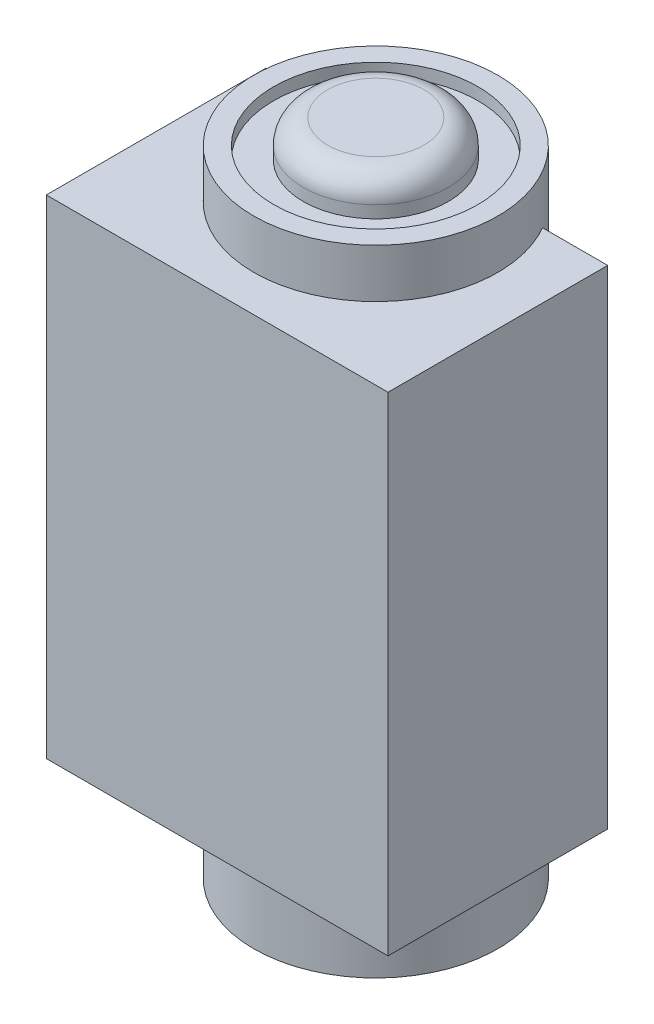
from build123d import *

# Parameters (mm, degrees)
BOSS_EXTRUDE1_DEPTH = 20
BOSS_EXTRUDE2_START = -4
SKETCH2_R           = 5
BOSS_EXTRUDE2_DEPTH = 26
SKETCH3_R           = 4.186334937
CUT_EXTRUDE1_DEPTH  = 0.5
SKETCH4_R           = 2.971370829
BOSS_EXTRUDE3_DEPTH = 1.5
FILLET1_R           = 1
SKETCH5_R           = 4.405236738
CUT_EXTRUDE2_DEPTH  = 0.25
SKETCH6_R           = 4.191211996
BOSS_EXTRUDE4_DEPTH = 0.25


with BuildPart() as part:
    # Sketch1 → Boss-Extrude1 (new body)
    with BuildSketch(Plane(origin=(0, 0, 0), x_dir=(1, 0, 0), z_dir=(0, 1, 0))):
        with BuildLine():
            Line((-4.330127019, 4.5), (-7, 4.5))
            Line((-7, 4.5), (-7, -4.5))
            Line((-7, -4.5), (7, -4.5))
            Line((7, -4.5), (7, 4.5))
            Line((7, 4.5), (4.330127019, 4.5))
            ThreePointArc((4.330127019, 4.5), (0, -3), (-4.330127019, 4.5))
        make_face()
    extrude(amount=BOSS_EXTRUDE1_DEPTH)


with BuildPart() as body_2:
    # Sketch2 → Boss-Extrude2 (new body)
    with BuildSketch(Plane(origin=(0, 0, 0), x_dir=(1, 0, 0), z_dir=(0, 1, 0)).offset(BOSS_EXTRUDE2_START)):
        with Locations((0, 2)):
            Circle(SKETCH2_R)
    extrude(amount=BOSS_EXTRUDE2_DEPTH)

    # Sketch3 → Cut-Extrude1 (cut)
    with BuildSketch(Plane(origin=(0, 22, 0), x_dir=(1, 0, 0), z_dir=(0, 1, 0))):
        with Locations((0, 2)):
            Circle(SKETCH3_R)
    extrude(amount=-CUT_EXTRUDE1_DEPTH, mode=Mode.SUBTRACT)

    # Sketch4 → Boss-Extrude3 (add)
    with BuildSketch(Plane(origin=(0, 21.5, 0), x_dir=(1, 0, 0), z_dir=(0, 1, 0))):
        with Locations((0, 2)):
            Circle(SKETCH4_R)
    extrude(amount=BOSS_EXTRUDE3_DEPTH)

    # Fillet1
    fillet1_edges = [body_2.edges().sort_by_distance(p)[0] for p in [
        (-2.971370829, 23, -2),
    ]]
    fillet(fillet1_edges, radius=FILLET1_R)

    # Sketch5 → Cut-Extrude2 (cut)
    with BuildSketch(Plane.XZ.offset(4)):
        with Locations((0, -2)):
            Circle(SKETCH5_R)
    extrude(amount=-CUT_EXTRUDE2_DEPTH, mode=Mode.SUBTRACT)


with BuildPart() as body_3:
    # Sketch6 → Boss-Extrude4 (new body)
    with BuildSketch(Plane.XZ.offset(3.75)):
        with Locations((0, -2)):
            Circle(SKETCH6_R)
    extrude(amount=BOSS_EXTRUDE4_DEPTH)


solid = Compound([part.part, body_2.part, body_3.part])
